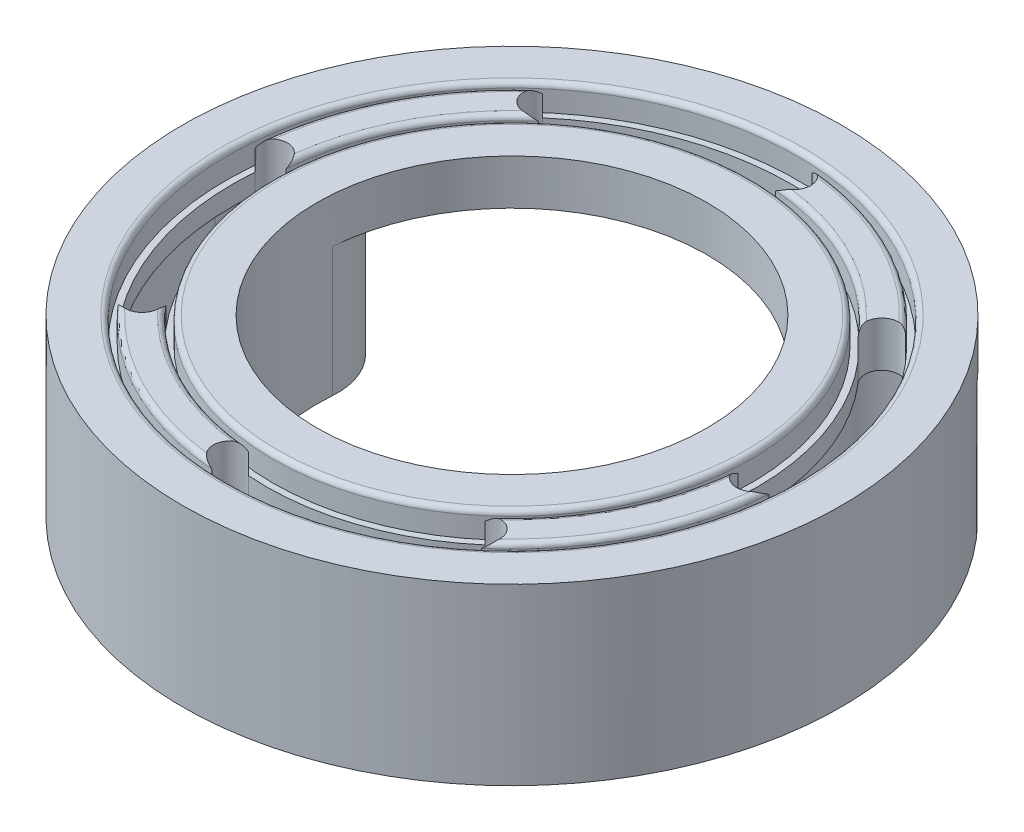
from build123d import *

# Parameters (mm, degrees)
SKETCH_1_R          = 25.5
EXTRUDE_1_DEPTH     = 3.5
SKETCH_2_R          = 19
SKETCH_2_R_2        = 18.5
CUT_EXTRUDE_1_DEPTH = 2
SKETCH_3_R          = 22.1
SKETCH_3_R_2        = 21.6
CUT_EXTRUDE_2_DEPTH = 2
FILLET_1_R          = 0.4
CUT_EXTRUDE_5_DEPTH = 37.231892039
EXTRUDE_2_DEPTH     = 10
SKETCH_6_R          = 15.1
CUT_EXTRUDE_6_DEPTH = 10


with BuildPart() as part:
    # 草图1 → 凸台-拉伸1 (new body)
    with BuildSketch(Plane(origin=(0, 0, 0), x_dir=(1, 0, 0), z_dir=(0, 1, 0))):
        with Locations(Location((0, 0, 0), (0, 0, 270))):
            Circle(SKETCH_1_R)
    extrude(amount=EXTRUDE_1_DEPTH)

    # 草图2 → 切除-拉伸1 (cut)
    with BuildSketch(Plane(origin=(0, 3.5, 0), x_dir=(1, 0, 0), z_dir=(0, 1, 0))):
        with Locations(Location((0, 0, 0), (0, 0, 270))):
            Circle(SKETCH_2_R)
        with Locations(Location((0, 0, 0), (0, 0, 270))):
            Circle(SKETCH_2_R_2, mode=Mode.SUBTRACT)
    extrude(amount=-CUT_EXTRUDE_1_DEPTH, mode=Mode.SUBTRACT)

    # 草图3 → 切除-拉伸2 (cut)
    with BuildSketch(Plane(origin=(0, 3.5, 0), x_dir=(1, 0, 0), z_dir=(0, 1, 0))):
        with Locations(Location((0, 0, 0), (0, 0, 270))):
            Circle(SKETCH_3_R)
        with Locations(Location((0, 0, 0), (0, 0, 270))):
            Circle(SKETCH_3_R_2, mode=Mode.SUBTRACT)
    extrude(amount=-CUT_EXTRUDE_2_DEPTH, mode=Mode.SUBTRACT)

    # 圆角1
    fillet_1_edges = [part.edges().sort_by_distance(p)[0] for p in [
        (0, 3.5, -22.1),
        (0, 3.5, -21.6),
        (0, 3.5, -19),
        (0, 3.5, -18.5),
    ]]
    fillet(fillet_1_edges, radius=FILLET_1_R)

    # 草图4 → 切除-拉伸5 (cut, through all)
    with BuildSketch(Plane.XZ):
        with BuildLine():
            ThreePointArc((-18.061657485, 5.897162783), (-18.865087187, 2.260195878), (-18.943542169, -1.463629086))
            ThreePointArc((-18.943542169, -1.463629086), (-20.139536222, -2.859909224), (-21.53581636, -1.663915171))
            ThreePointArc((-21.53581636, -1.663915171), (-21.446625434, 2.569485841), (-20.53325272, 6.704142953))
            ThreePointArc((-20.53325272, 6.704142953), (-18.830798619, 10.581163611), (-16.404687488, 14.051556086))
            ThreePointArc((-16.404687488, 14.051556086), (-14.571672828, 14.193179735), (-14.430049179, 12.360165075))
            ThreePointArc((-14.430049179, 12.360165075), (-16.564128415, 9.307505028), (-18.061657485, 5.897162783))
        make_face()
        with BuildLine():
            ThreePointArc((-1.663915171, 21.53581636), (-2.859909224, 20.139536222), (-1.463629086, 18.943542169))
            ThreePointArc((-1.463629086, 18.943542169), (5.897162783, 18.061657485), (12.360165075, 14.430049179))
            ThreePointArc((12.360165075, 14.430049179), (14.193179735, 14.571672828), (14.051556086, 16.404687488))
            ThreePointArc((14.051556086, 16.404687488), (6.704142953, 20.53325272), (-1.663915171, 21.53581636))
        make_face()
        with BuildLine():
            ThreePointArc((21.53581636, 1.663915171), (20.139536222, 2.859909224), (18.943542169, 1.463629086))
            ThreePointArc((18.943542169, 1.463629086), (18.865087187, -2.260195878), (18.061657485, -5.897162783))
            ThreePointArc((18.061657485, -5.897162783), (16.564128415, -9.307505028), (14.430049179, -12.360165075))
            ThreePointArc((14.430049179, -12.360165075), (14.571672828, -14.193179735), (16.404687488, -14.051556086))
            ThreePointArc((16.404687488, -14.051556086), (18.830798619, -10.581163611), (20.53325272, -6.704142953))
            ThreePointArc((20.53325272, -6.704142953), (21.446625434, -2.569485841), (21.53581636, 1.663915171))
        make_face()
        with BuildLine():
            ThreePointArc((1.663915171, -21.53581636), (2.859909224, -20.139536222), (1.463629086, -18.943542169))
            ThreePointArc((1.463629086, -18.943542169), (-5.897162783, -18.061657485), (-12.360165075, -14.430049179))
            ThreePointArc((-12.360165075, -14.430049179), (-14.193179735, -14.571672828), (-14.051556086, -16.404687488))
            ThreePointArc((-14.051556086, -16.404687488), (-6.704142953, -20.53325272), (1.663915171, -21.53581636))
        make_face()
    extrude(amount=-CUT_EXTRUDE_5_DEPTH, mode=Mode.SUBTRACT)

    # 草图5 → 凸台-拉伸2 (add)
    with BuildSketch(Plane.XZ):
        with BuildLine():
            ThreePointArc((19.366644951, -16.588642601), (7.914613208, 24.240645572), (-25.424227648, -1.964344299))
            ThreePointArc((-25.424227648, -1.964344299), (-19.839107094, -6.748320512), (-15.055130881, -1.163199958))
            ThreePointArc((-15.055130881, -1.163199958), (4.686692527, 14.354264633), (11.468091716, -9.82307856))
            ThreePointArc((11.468091716, -9.82307856), (12.034586313, -17.155137198), (19.366644951, -16.588642601))
        make_face()
        with BuildLine():
            ThreePointArc((18.986906814, -16.263375099), (7.759424714, 23.765338796), (-24.92571338, -1.925827745))
            ThreePointArc((-24.92571338, -1.925827745), (-19.877623649, -6.249806244), (-15.553645149, -1.201716513))
            ThreePointArc((-15.553645149, -1.201716513), (4.841881022, 14.829571409), (11.847829852, -10.148346062))
            ThreePointArc((11.847829852, -10.148346062), (12.359853815, -16.775399062), (18.986906814, -16.263375099))
        make_face(mode=Mode.SUBTRACT)
    extrude(amount=EXTRUDE_2_DEPTH)

    # 草图6 → 切除-拉伸6 (cut)
    with BuildSketch(Plane.XZ):
        with Locations(Location((0, 0, 0), (0, 0, 90))):
            Circle(SKETCH_6_R)
    extrude(amount=-CUT_EXTRUDE_6_DEPTH, mode=Mode.SUBTRACT)


solid = part.part
